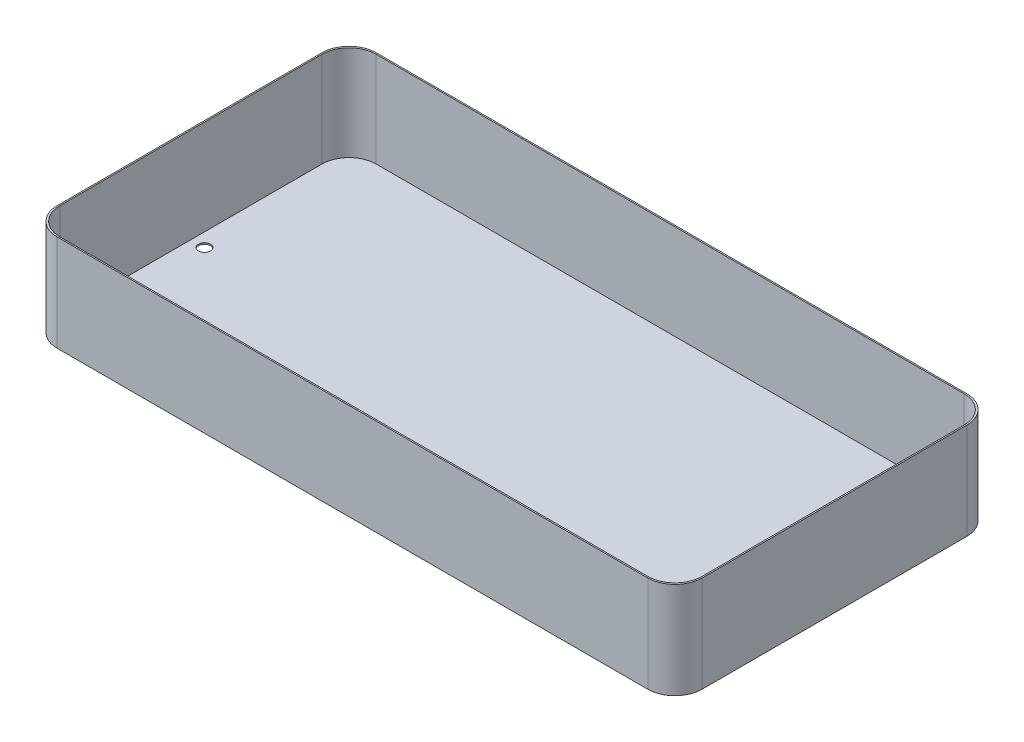
from build123d import *

# Parameters (mm, degrees)
SKETCH1_W                        = 1206.5
SKETCH1_H                        = 596.9
SKETCH1_W_2                      = 1201.42
SKETCH1_H_2                      = 591.82
BOSS_EXTRUDE1_DEPTH              = 177.8
SKETCH2_W                        = 1206.5
SKETCH2_H                        = 596.9
BOSS_EXTRUDE2_DEPTH              = 2.54
FILLET1_R                        = 50.8
F_7_8_0_875_DIAMETER_HOLE1_D     = 22.225
F_7_8_0_875_DIAMETER_HOLE1_DEPTH = 2.54


with BuildPart() as part:
    # Sketch1 → Boss-Extrude1 (new body)
    with BuildSketch(Plane(origin=(0, 0, 0), x_dir=(1, 0, 0), z_dir=(0, 1, 0))):
        Rectangle(SKETCH1_W, SKETCH1_H)
        Rectangle(SKETCH1_W_2, SKETCH1_H_2, mode=Mode.SUBTRACT)
    extrude(amount=BOSS_EXTRUDE1_DEPTH)

    # Sketch2 → Boss-Extrude2 (add)
    with BuildSketch(Plane.XZ):
        Rectangle(SKETCH2_W, SKETCH2_H)
    extrude(amount=BOSS_EXTRUDE2_DEPTH)

    # Fillet1
    fillet1_edges = [part.edges().sort_by_distance(p)[0] for p in [
        (600.71, 88.9, 295.91),
        (600.71, 88.9, -295.91),
        (-600.71, 88.9, -295.91),
        (-600.71, 88.9, 295.91),
        (603.25, 87.63, 298.45),
        (-603.25, 87.63, 298.45),
        (-603.25, 87.63, -298.45),
        (603.25, 87.63, -298.45),
    ]]
    fillet(fillet1_edges, radius=FILLET1_R)

    # 7/8 (0.875) Diameter Hole1
    with Locations(Plane(origin=(0, 0, 0), x_dir=(1, 0, 0), z_dir=(0, 1, 0))):
        with Locations((575.31, 0), (-575.31, 0)):
            Hole(F_7_8_0_875_DIAMETER_HOLE1_D / 2, depth=F_7_8_0_875_DIAMETER_HOLE1_DEPTH)


solid = part.part
